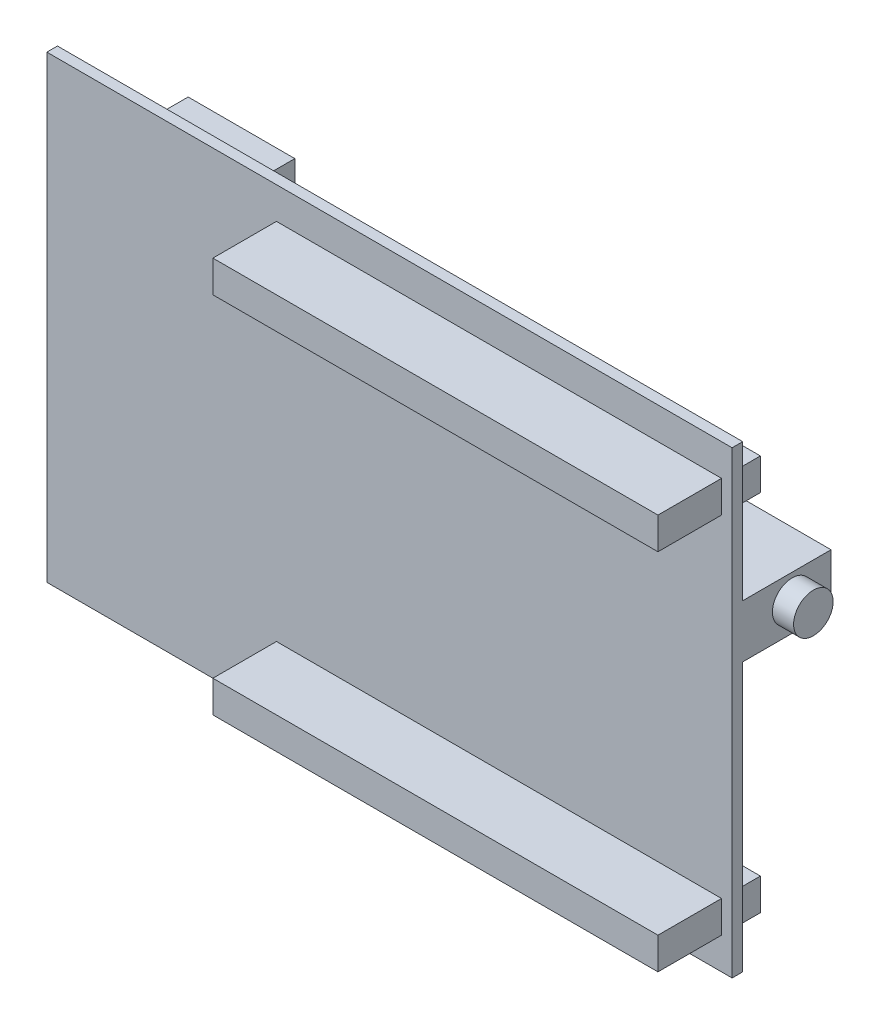
from build123d import *

# Parameters (mm, degrees)
SKETCH1_W                = 97
SKETCH1_H                = 65
BOSS_EXTRUDE1_DEPTH      = 1.5
SKETCH2_W                = 63
SKETCH2_H                = 4.5
BOSS_EXTRUDE2_DEPTH      = 4
BOSS_EXTRUDE2_DEPTH_BACK = 10.5
SKETCH3_W                = 13.5
SKETCH3_H                = 7.5
BOSS_EXTRUDE3_DEPTH      = 12.5
SKETCH4_R                = 2.8
BOSS_EXTRUDE4_DEPTH      = 3
SKETCH5_W                = 4.5
SKETCH5_H                = 1.5
BOSS_EXTRUDE5_DEPTH      = 4
SKETCH6_W                = 15.1
SKETCH6_H                = 3
BOSS_EXTRUDE6_DEPTH      = 8.5
SKETCH7_W                = 10
SKETCH7_H                = 2
BOSS_EXTRUDE7_DEPTH      = 8.5
SKETCH8_W                = 5.5
SKETCH8_H                = 2
BOSS_EXTRUDE8_DEPTH      = 8.5
SKETCH9_W                = 6
SKETCH9_H                = 6
BOSS_EXTRUDE9_DEPTH      = 4
SKETCH10_R               = 2.5
BOSS_EXTRUDE10_DEPTH     = 6
SKETCH13_R               = 2.5
BOSS_EXTRUDE11_DEPTH     = 6


with BuildPart() as part:
    # Sketch1 → Boss-Extrude1 (new body)
    with BuildSketch(Plane.XY):
        Rectangle(SKETCH1_W, SKETCH1_H)
    extrude(amount=BOSS_EXTRUDE1_DEPTH)

    # Sketch2 → Boss-Extrude2 (add, two sides)
    with BuildSketch(Plane(origin=(0, 0, 0), x_dir=(-1, 0, 0), z_dir=(0, 0, -1))) as boss_extrude2_sk:
        with Locations((-15.5, 25.75)):
            Rectangle(SKETCH2_W, SKETCH2_H)
        with Locations((-15.5, -25.75)):
            Rectangle(SKETCH2_W, SKETCH2_H)
    extrude(amount=BOSS_EXTRUDE2_DEPTH)
    extrude(boss_extrude2_sk.sketch, amount=-BOSS_EXTRUDE2_DEPTH_BACK)

    # Sketch3 → Boss-Extrude3 (add)
    with BuildSketch(Plane(origin=(0, 0, 0), x_dir=(-1, 0, 0), z_dir=(0, 0, -1))):
        with Locations((-41.75, 9.25)):
            Rectangle(SKETCH3_W, SKETCH3_H)
    extrude(amount=BOSS_EXTRUDE3_DEPTH)

    # Sketch4 → Boss-Extrude4 (add)
    with BuildSketch(Plane(origin=(48.5, 0, 0), x_dir=(0, 0, -1), z_dir=(1, 0, 0))):
        with Locations((7, 9.5)):
            Circle(SKETCH4_R)
    extrude(amount=BOSS_EXTRUDE4_DEPTH)

    # Sketch5 → Boss-Extrude5 (add)
    with BuildSketch(Plane(origin=(0, 0, 0), x_dir=(-1, 0, 0), z_dir=(0, 0, -1))):
        with Locations((44.25, -26.080181332)):
            Rectangle(SKETCH5_W, SKETCH5_H)
        with Locations((44.25, 26.080181332)):
            Rectangle(SKETCH5_W, SKETCH5_H)
    extrude(amount=BOSS_EXTRUDE5_DEPTH)

    # Sketch6 → Boss-Extrude6 (add)
    with BuildSketch(Plane(origin=(0, 0, 0), x_dir=(-1, 0, 0), z_dir=(0, 0, -1))):
        with Locations((30.95, 25.5)):
            Rectangle(SKETCH6_W, SKETCH6_H)
    extrude(amount=BOSS_EXTRUDE6_DEPTH)

    # Sketch7 → Boss-Extrude7 (add)
    with BuildSketch(Plane(origin=(0, 0, 0), x_dir=(-1, 0, 0), z_dir=(0, 0, -1))):
        with Locations((28.5, -15.5)):
            Rectangle(SKETCH7_W, SKETCH7_H)
    extrude(amount=BOSS_EXTRUDE7_DEPTH)

    # Sketch8 → Boss-Extrude8 (add)
    with BuildSketch(Plane(origin=(0, 0, 0), x_dir=(-1, 0, 0), z_dir=(0, 0, -1))):
        with Locations((6.25, 15.5)):
            Rectangle(SKETCH8_W, SKETCH8_H)
    extrude(amount=BOSS_EXTRUDE8_DEPTH)

    # Sketch9 → Boss-Extrude9 (add)
    with BuildSketch(Plane(origin=(0, 0, 0), x_dir=(-1, 0, 0), z_dir=(0, 0, -1))):
        with Locations((-16.5, -14.5)):
            Rectangle(SKETCH9_W, SKETCH9_H)
        with Locations((-16.5, 14.5)):
            Rectangle(SKETCH9_W, SKETCH9_H)
    extrude(amount=BOSS_EXTRUDE9_DEPTH)

    # Sketch10 → Boss-Extrude10 (add)
    with BuildSketch(Plane(origin=(0, 0, -4), x_dir=(-1, 0, 0), z_dir=(0, 0, -1))):
        with Locations((-16.5, 14.5)):
            Circle(SKETCH10_R)
    extrude(amount=BOSS_EXTRUDE10_DEPTH)

    # Sketch13 → Boss-Extrude11 (add)
    with BuildSketch(Plane(origin=(0, 0, -4), x_dir=(-1, 0, 0), z_dir=(0, 0, -1))):
        with Locations((-16.5, -14.5)):
            Circle(SKETCH13_R)
    extrude(amount=BOSS_EXTRUDE11_DEPTH)


solid = part.part
